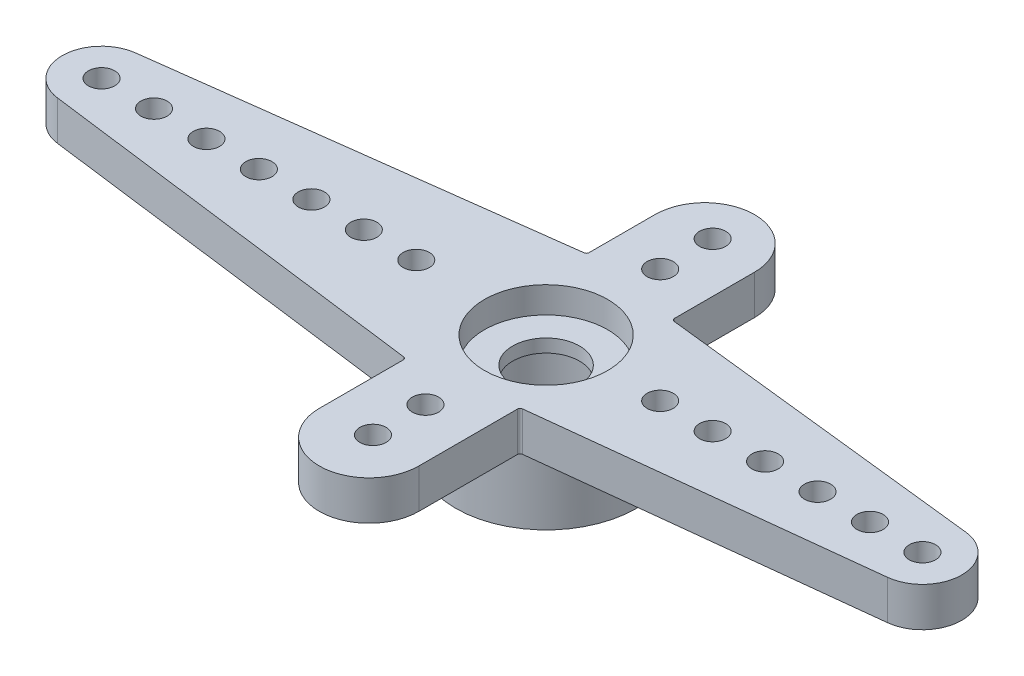
from build123d import *

# Parameters (mm, degrees)
IZIM1_R                     = 0.5
IZIM1_R_2                   = 2.35
Y_KSEKLIK_EKSTR_ZYON1_DEPTH = 1.5
IZIM1_3_R                   = 2.35
IZIM1_3_R_2                 = 1.275
Y_KSEKLIK_EKSTR_ZYON2_DEPTH = 0.5
IZIM2_R                     = 3.45
IZIM2_R_2                   = 2.3
Y_KSEKLIK_EKSTR_ZYON3_DEPTH = 2.5
RADYUS1_R                   = 0.1


with BuildPart() as part:
    # Çizim1 → Yükseklik-Ekstrüzyon1 (new body)
    with BuildSketch(Plane(origin=(0, 0, 0), x_dir=(1, 0, 0), z_dir=(0, 1, 0))):
        with BuildLine():
            ThreePointArc((1.9, 6.05), (0, 7.95), (-1.9, 6.05))
            Line((-1.9, 6.05), (-1.9, 3.45))
            Line((-1.9, 3.45), (-17.141537347, 1.487720889))
            ThreePointArc((-17.141537347, 1.487720889), (-18.45, 0), (-17.141537347, -1.487720889))
            Line((-17.141537347, -1.487720889), (-1.9, -3.45))
            Line((-1.9, -3.45), (-1.9, -6.75))
            ThreePointArc((-1.9, -6.75), (0, -8.65), (1.9, -6.75))
            Line((1.9, -6.75), (1.9, -2.9))
            Line((1.9, -2.9), (14.516515169, -1.490728915))
            ThreePointArc((14.516515169, -1.490728915), (15.85, 0), (14.516515169, 1.490728915))
            Line((14.516515169, 1.490728915), (1.9, 2.9))
            Line((1.9, 2.9), (1.9, 6.05))
        make_face()
        with Locations((0, -6.6)):
            Circle(IZIM1_R, mode=Mode.SUBTRACT)
        with Locations((0, -4.6)):
            Circle(IZIM1_R, mode=Mode.SUBTRACT)
        with Locations((-16.95, 0)):
            Circle(IZIM1_R, mode=Mode.SUBTRACT)
        with Locations((-14.95, 0)):
            Circle(IZIM1_R, mode=Mode.SUBTRACT)
        with Locations((-12.95, 0)):
            Circle(IZIM1_R, mode=Mode.SUBTRACT)
        with Locations((-10.95, 0)):
            Circle(IZIM1_R, mode=Mode.SUBTRACT)
        with Locations((-8.95, 0)):
            Circle(IZIM1_R, mode=Mode.SUBTRACT)
        with Locations((-6.95, 0)):
            Circle(IZIM1_R, mode=Mode.SUBTRACT)
        with Locations((-4.95, 0)):
            Circle(IZIM1_R, mode=Mode.SUBTRACT)
        Circle(IZIM1_R_2, mode=Mode.SUBTRACT)
        with Locations((4.35, 0)):
            Circle(IZIM1_R, mode=Mode.SUBTRACT)
        with Locations((6.35, 0)):
            Circle(IZIM1_R, mode=Mode.SUBTRACT)
        with Locations((8.35, 0)):
            Circle(IZIM1_R, mode=Mode.SUBTRACT)
        with Locations((10.35, 0)):
            Circle(IZIM1_R, mode=Mode.SUBTRACT)
        with Locations((12.35, 0)):
            Circle(IZIM1_R, mode=Mode.SUBTRACT)
        with Locations((14.35, 0)):
            Circle(IZIM1_R, mode=Mode.SUBTRACT)
        with Locations((0, 4.35)):
            Circle(IZIM1_R, mode=Mode.SUBTRACT)
        with Locations((0, 6.35)):
            Circle(IZIM1_R, mode=Mode.SUBTRACT)
    extrude(amount=Y_KSEKLIK_EKSTR_ZYON1_DEPTH)

    # Çizim1<3> → Yükseklik-Ekstrüzyon2 (add)
    with BuildSketch(Plane(origin=(0, 0, 0), x_dir=(1, 0, 0), z_dir=(0, 1, 0))):
        Circle(IZIM1_3_R)
        Circle(IZIM1_3_R_2, mode=Mode.SUBTRACT)
    extrude(amount=Y_KSEKLIK_EKSTR_ZYON2_DEPTH)

    # Çizim2 → Yükseklik-Ekstrüzyon3 (add)
    with BuildSketch(Plane.XZ):
        Circle(IZIM2_R)
        Circle(IZIM2_R_2, mode=Mode.SUBTRACT)
    extrude(amount=Y_KSEKLIK_EKSTR_ZYON3_DEPTH)

    # Radyus1
    radyus1_edges = [part.edges().sort_by_distance(p)[0] for p in [
        (-1.9, 0.75, -3.45),
        (1.9, 0.75, -2.9),
        (1.9, 0.75, 2.9),
        (-1.9, 0.75, 3.45),
    ]]
    fillet(radyus1_edges, radius=RADYUS1_R)


solid = part.part
